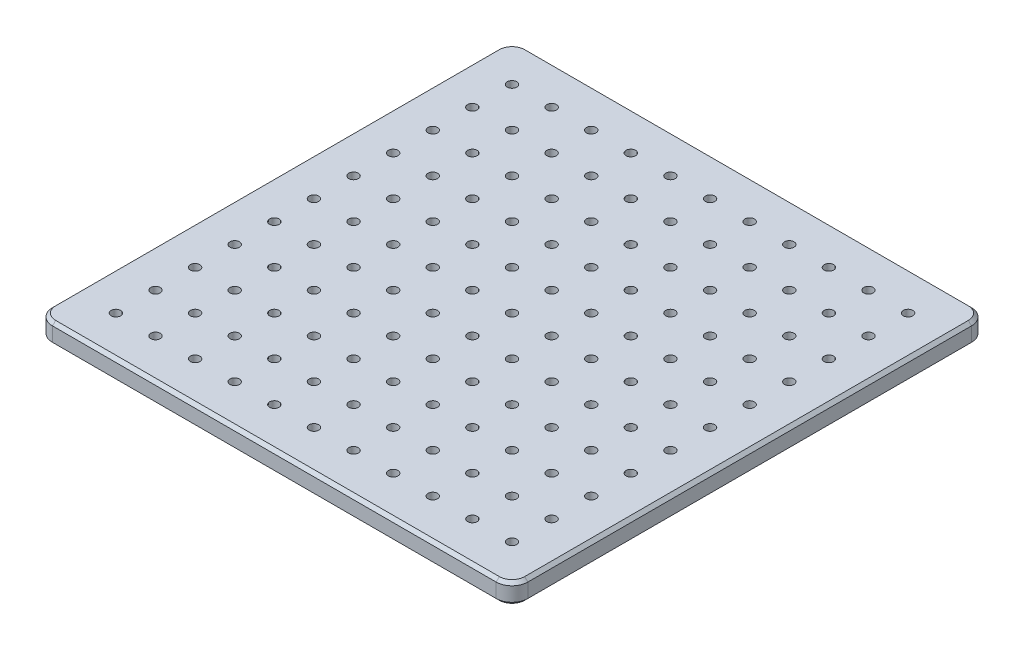
from build123d import *

# Parameters (mm, degrees)
SKETCH_1_R      = 3
EXTRUDE_1_DEPTH = 13
CHAMFER_1_SIZE  = 2


with BuildPart() as part:
    # 草图1 → 凸台-拉伸1 (new body)
    with BuildSketch(Plane(origin=(0, 0, 0), x_dir=(1, 0, 0), z_dir=(0, 1, 0))):
        with BuildLine():
            Line((-140, 150), (140, 150))
            ThreePointArc((140, 150), (147.071067812, 147.071067812), (150, 140))
            Line((150, 140), (150, -140))
            ThreePointArc((150, -140), (147.071067812, -147.071067812), (140, -150))
            Line((140, -150), (-140, -150))
            ThreePointArc((-140, -150), (-147.071067812, -147.071067812), (-150, -140))
            Line((-150, -140), (-150, 140))
            ThreePointArc((-150, 140), (-147.071067812, 147.071067812), (-140, 150))
        make_face()
        with Locations((-125, 125)):
            Circle(SKETCH_1_R, mode=Mode.SUBTRACT)
        with Locations((-100, 125)):
            Circle(SKETCH_1_R, mode=Mode.SUBTRACT)
        with Locations((-75, 125)):
            Circle(SKETCH_1_R, mode=Mode.SUBTRACT)
        with Locations((-50, 125)):
            Circle(SKETCH_1_R, mode=Mode.SUBTRACT)
        with Locations((-25, 125)):
            Circle(SKETCH_1_R, mode=Mode.SUBTRACT)
        with Locations((0, 125)):
            Circle(SKETCH_1_R, mode=Mode.SUBTRACT)
        with Locations((25, 125)):
            Circle(SKETCH_1_R, mode=Mode.SUBTRACT)
        with Locations((50, 125)):
            Circle(SKETCH_1_R, mode=Mode.SUBTRACT)
        with Locations((75, 125)):
            Circle(SKETCH_1_R, mode=Mode.SUBTRACT)
        with Locations((100, 125)):
            Circle(SKETCH_1_R, mode=Mode.SUBTRACT)
        with Locations((125, 125)):
            Circle(SKETCH_1_R, mode=Mode.SUBTRACT)
        with Locations((125, 100)):
            Circle(SKETCH_1_R, mode=Mode.SUBTRACT)
        with Locations((100, 100)):
            Circle(SKETCH_1_R, mode=Mode.SUBTRACT)
        with Locations((75, 100)):
            Circle(SKETCH_1_R, mode=Mode.SUBTRACT)
        with Locations((50, 100)):
            Circle(SKETCH_1_R, mode=Mode.SUBTRACT)
        with Locations((25, 100)):
            Circle(SKETCH_1_R, mode=Mode.SUBTRACT)
        with Locations((0, 100)):
            Circle(SKETCH_1_R, mode=Mode.SUBTRACT)
        with Locations((-25, 100)):
            Circle(SKETCH_1_R, mode=Mode.SUBTRACT)
        with Locations((-50, 100)):
            Circle(SKETCH_1_R, mode=Mode.SUBTRACT)
        with Locations((-75, 100)):
            Circle(SKETCH_1_R, mode=Mode.SUBTRACT)
        with Locations((-100, 100)):
            Circle(SKETCH_1_R, mode=Mode.SUBTRACT)
        with Locations((-125, 100)):
            Circle(SKETCH_1_R, mode=Mode.SUBTRACT)
        with Locations((125, 75)):
            Circle(SKETCH_1_R, mode=Mode.SUBTRACT)
        with Locations((100, 75)):
            Circle(SKETCH_1_R, mode=Mode.SUBTRACT)
        with Locations((75, 75)):
            Circle(SKETCH_1_R, mode=Mode.SUBTRACT)
        with Locations((50, 75)):
            Circle(SKETCH_1_R, mode=Mode.SUBTRACT)
        with Locations((25, 75)):
            Circle(SKETCH_1_R, mode=Mode.SUBTRACT)
        with Locations((0, 75)):
            Circle(SKETCH_1_R, mode=Mode.SUBTRACT)
        with Locations((-25, 75)):
            Circle(SKETCH_1_R, mode=Mode.SUBTRACT)
        with Locations((-50, 75)):
            Circle(SKETCH_1_R, mode=Mode.SUBTRACT)
        with Locations((-75, 75)):
            Circle(SKETCH_1_R, mode=Mode.SUBTRACT)
        with Locations((-100, 75)):
            Circle(SKETCH_1_R, mode=Mode.SUBTRACT)
        with Locations((-125, 75)):
            Circle(SKETCH_1_R, mode=Mode.SUBTRACT)
        with Locations((125, 50)):
            Circle(SKETCH_1_R, mode=Mode.SUBTRACT)
        with Locations((100, 50)):
            Circle(SKETCH_1_R, mode=Mode.SUBTRACT)
        with Locations((75, 50)):
            Circle(SKETCH_1_R, mode=Mode.SUBTRACT)
        with Locations((50, 50)):
            Circle(SKETCH_1_R, mode=Mode.SUBTRACT)
        with Locations((25, 50)):
            Circle(SKETCH_1_R, mode=Mode.SUBTRACT)
        with Locations((0, 50)):
            Circle(SKETCH_1_R, mode=Mode.SUBTRACT)
        with Locations((-25, 50)):
            Circle(SKETCH_1_R, mode=Mode.SUBTRACT)
        with Locations((-50, 50)):
            Circle(SKETCH_1_R, mode=Mode.SUBTRACT)
        with Locations((-75, 50)):
            Circle(SKETCH_1_R, mode=Mode.SUBTRACT)
        with Locations((-100, 50)):
            Circle(SKETCH_1_R, mode=Mode.SUBTRACT)
        with Locations((-125, 50)):
            Circle(SKETCH_1_R, mode=Mode.SUBTRACT)
        with Locations((125, 25)):
            Circle(SKETCH_1_R, mode=Mode.SUBTRACT)
        with Locations((100, 25)):
            Circle(SKETCH_1_R, mode=Mode.SUBTRACT)
        with Locations((75, 25)):
            Circle(SKETCH_1_R, mode=Mode.SUBTRACT)
        with Locations((50, 25)):
            Circle(SKETCH_1_R, mode=Mode.SUBTRACT)
        with Locations((25, 25)):
            Circle(SKETCH_1_R, mode=Mode.SUBTRACT)
        with Locations((0, 25)):
            Circle(SKETCH_1_R, mode=Mode.SUBTRACT)
        with Locations((-25, 25)):
            Circle(SKETCH_1_R, mode=Mode.SUBTRACT)
        with Locations((-50, 25)):
            Circle(SKETCH_1_R, mode=Mode.SUBTRACT)
        with Locations((-75, 25)):
            Circle(SKETCH_1_R, mode=Mode.SUBTRACT)
        with Locations((-100, 25)):
            Circle(SKETCH_1_R, mode=Mode.SUBTRACT)
        with Locations((-125, 25)):
            Circle(SKETCH_1_R, mode=Mode.SUBTRACT)
        with Locations((125, 0)):
            Circle(SKETCH_1_R, mode=Mode.SUBTRACT)
        with Locations((100, 0)):
            Circle(SKETCH_1_R, mode=Mode.SUBTRACT)
        with Locations((75, 0)):
            Circle(SKETCH_1_R, mode=Mode.SUBTRACT)
        with Locations((50, 0)):
            Circle(SKETCH_1_R, mode=Mode.SUBTRACT)
        with Locations((25, 0)):
            Circle(SKETCH_1_R, mode=Mode.SUBTRACT)
        Circle(SKETCH_1_R, mode=Mode.SUBTRACT)
        with Locations((-25, 0)):
            Circle(SKETCH_1_R, mode=Mode.SUBTRACT)
        with Locations((-50, 0)):
            Circle(SKETCH_1_R, mode=Mode.SUBTRACT)
        with Locations((-75, 0)):
            Circle(SKETCH_1_R, mode=Mode.SUBTRACT)
        with Locations((-100, 0)):
            Circle(SKETCH_1_R, mode=Mode.SUBTRACT)
        with Locations((-125, 0)):
            Circle(SKETCH_1_R, mode=Mode.SUBTRACT)
        with Locations((125, -25)):
            Circle(SKETCH_1_R, mode=Mode.SUBTRACT)
        with Locations((100, -25)):
            Circle(SKETCH_1_R, mode=Mode.SUBTRACT)
        with Locations((75, -25)):
            Circle(SKETCH_1_R, mode=Mode.SUBTRACT)
        with Locations((50, -25)):
            Circle(SKETCH_1_R, mode=Mode.SUBTRACT)
        with Locations((25, -25)):
            Circle(SKETCH_1_R, mode=Mode.SUBTRACT)
        with Locations((0, -25)):
            Circle(SKETCH_1_R, mode=Mode.SUBTRACT)
        with Locations((-25, -25)):
            Circle(SKETCH_1_R, mode=Mode.SUBTRACT)
        with Locations((-50, -25)):
            Circle(SKETCH_1_R, mode=Mode.SUBTRACT)
        with Locations((-75, -25)):
            Circle(SKETCH_1_R, mode=Mode.SUBTRACT)
        with Locations((-100, -25)):
            Circle(SKETCH_1_R, mode=Mode.SUBTRACT)
        with Locations((-125, -25)):
            Circle(SKETCH_1_R, mode=Mode.SUBTRACT)
        with Locations((125, -50)):
            Circle(SKETCH_1_R, mode=Mode.SUBTRACT)
        with Locations((100, -50)):
            Circle(SKETCH_1_R, mode=Mode.SUBTRACT)
        with Locations((75, -50)):
            Circle(SKETCH_1_R, mode=Mode.SUBTRACT)
        with Locations((50, -50)):
            Circle(SKETCH_1_R, mode=Mode.SUBTRACT)
        with Locations((25, -50)):
            Circle(SKETCH_1_R, mode=Mode.SUBTRACT)
        with Locations((0, -50)):
            Circle(SKETCH_1_R, mode=Mode.SUBTRACT)
        with Locations((-25, -50)):
            Circle(SKETCH_1_R, mode=Mode.SUBTRACT)
        with Locations((-50, -50)):
            Circle(SKETCH_1_R, mode=Mode.SUBTRACT)
        with Locations((-75, -50)):
            Circle(SKETCH_1_R, mode=Mode.SUBTRACT)
        with Locations((-100, -50)):
            Circle(SKETCH_1_R, mode=Mode.SUBTRACT)
        with Locations((-125, -50)):
            Circle(SKETCH_1_R, mode=Mode.SUBTRACT)
        with Locations((125, -75)):
            Circle(SKETCH_1_R, mode=Mode.SUBTRACT)
        with Locations((100, -75)):
            Circle(SKETCH_1_R, mode=Mode.SUBTRACT)
        with Locations((75, -75)):
            Circle(SKETCH_1_R, mode=Mode.SUBTRACT)
        with Locations((50, -75)):
            Circle(SKETCH_1_R, mode=Mode.SUBTRACT)
        with Locations((25, -75)):
            Circle(SKETCH_1_R, mode=Mode.SUBTRACT)
        with Locations((0, -75)):
            Circle(SKETCH_1_R, mode=Mode.SUBTRACT)
        with Locations((-25, -75)):
            Circle(SKETCH_1_R, mode=Mode.SUBTRACT)
        with Locations((-50, -75)):
            Circle(SKETCH_1_R, mode=Mode.SUBTRACT)
        with Locations((-75, -75)):
            Circle(SKETCH_1_R, mode=Mode.SUBTRACT)
        with Locations((-100, -75)):
            Circle(SKETCH_1_R, mode=Mode.SUBTRACT)
        with Locations((-125, -75)):
            Circle(SKETCH_1_R, mode=Mode.SUBTRACT)
        with Locations((125, -100)):
            Circle(SKETCH_1_R, mode=Mode.SUBTRACT)
        with Locations((100, -100)):
            Circle(SKETCH_1_R, mode=Mode.SUBTRACT)
        with Locations((75, -100)):
            Circle(SKETCH_1_R, mode=Mode.SUBTRACT)
        with Locations((50, -100)):
            Circle(SKETCH_1_R, mode=Mode.SUBTRACT)
        with Locations((25, -100)):
            Circle(SKETCH_1_R, mode=Mode.SUBTRACT)
        with Locations((0, -100)):
            Circle(SKETCH_1_R, mode=Mode.SUBTRACT)
        with Locations((-25, -100)):
            Circle(SKETCH_1_R, mode=Mode.SUBTRACT)
        with Locations((-50, -100)):
            Circle(SKETCH_1_R, mode=Mode.SUBTRACT)
        with Locations((-75, -100)):
            Circle(SKETCH_1_R, mode=Mode.SUBTRACT)
        with Locations((-100, -100)):
            Circle(SKETCH_1_R, mode=Mode.SUBTRACT)
        with Locations((-125, -100)):
            Circle(SKETCH_1_R, mode=Mode.SUBTRACT)
        with Locations((125, -125)):
            Circle(SKETCH_1_R, mode=Mode.SUBTRACT)
        with Locations((100, -125)):
            Circle(SKETCH_1_R, mode=Mode.SUBTRACT)
        with Locations((75, -125)):
            Circle(SKETCH_1_R, mode=Mode.SUBTRACT)
        with Locations((50, -125)):
            Circle(SKETCH_1_R, mode=Mode.SUBTRACT)
        with Locations((25, -125)):
            Circle(SKETCH_1_R, mode=Mode.SUBTRACT)
        with Locations((0, -125)):
            Circle(SKETCH_1_R, mode=Mode.SUBTRACT)
        with Locations((-25, -125)):
            Circle(SKETCH_1_R, mode=Mode.SUBTRACT)
        with Locations((-50, -125)):
            Circle(SKETCH_1_R, mode=Mode.SUBTRACT)
        with Locations((-75, -125)):
            Circle(SKETCH_1_R, mode=Mode.SUBTRACT)
        with Locations((-100, -125)):
            Circle(SKETCH_1_R, mode=Mode.SUBTRACT)
        with Locations((-125, -125)):
            Circle(SKETCH_1_R, mode=Mode.SUBTRACT)
    extrude(amount=EXTRUDE_1_DEPTH)

    # 倒角1
    chamfer_1_edges = [part.edges().sort_by_distance(p)[0] for p in [
        (0, 0, 150),
        (-147.071067812, 0, 147.071067812),
        (-150, 0, 0),
        (-147.071067812, 0, -147.071067812),
        (-147.071067812, 13, 147.071067812),
        (0, 13, 150),
        (147.071067812, 13, 147.071067812),
        (150, 13, 0),
        (147.071067812, 13, -147.071067812),
        (0, 13, -150),
        (-147.071067812, 13, -147.071067812),
        (0, 0, -150),
        (-150, 13, 0),
        (147.071067812, 0, -147.071067812),
        (150, 0, 0),
        (147.071067812, 0, 147.071067812),
    ]]
    chamfer(chamfer_1_edges, length=CHAMFER_1_SIZE)


solid = part.part
